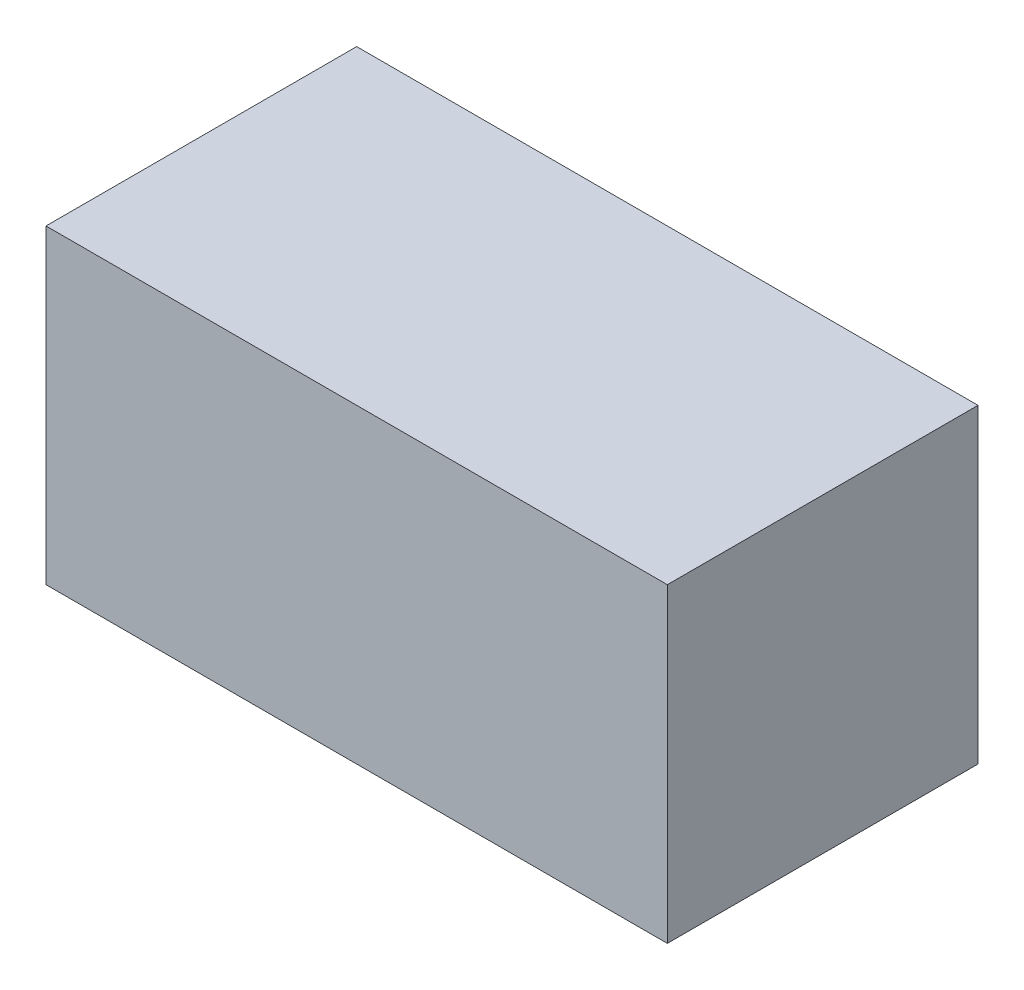
from build123d import *

# Parameters (mm, degrees)
SKETCH1_W           = 2
SKETCH1_H           = 1
BOSS_EXTRUDE1_DEPTH = 1


with BuildPart() as part:
    # Sketch1 → Boss-Extrude1 (new body)
    with BuildSketch(Plane.XY):
        Rectangle(SKETCH1_W, SKETCH1_H)
    extrude(amount=BOSS_EXTRUDE1_DEPTH)


solid = part.part
